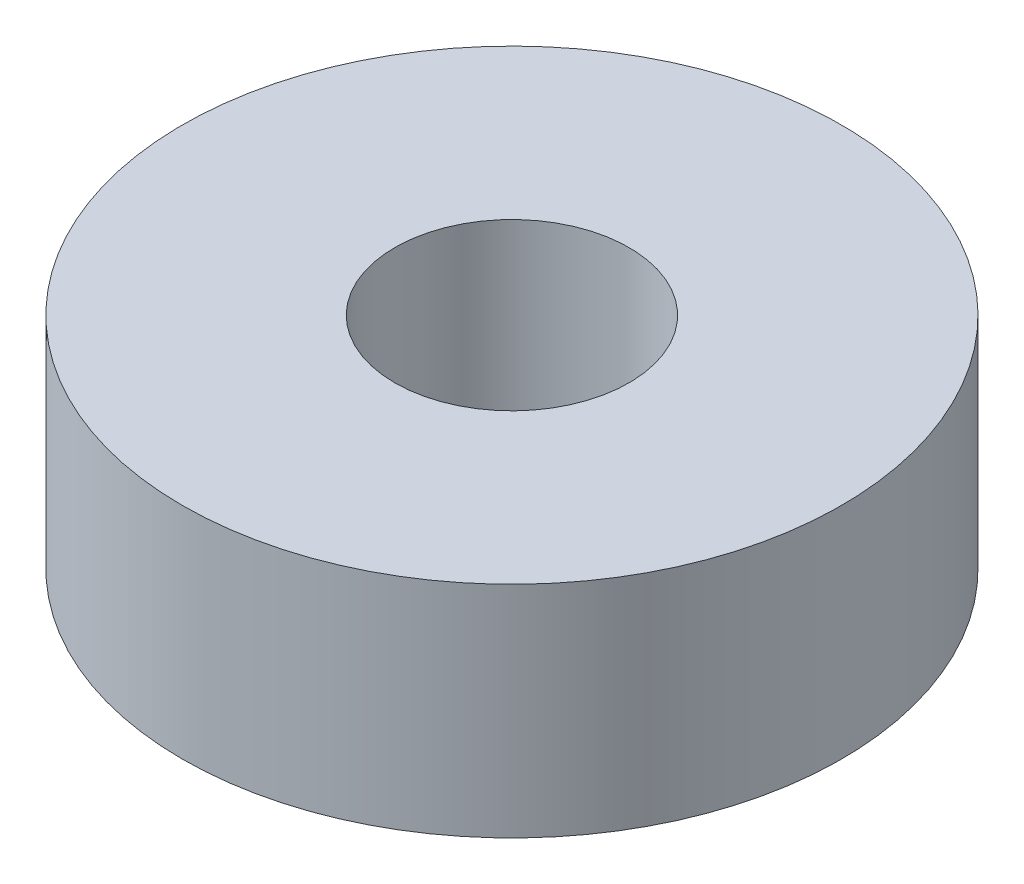
from build123d import *

# Parameters (mm, degrees)
SKETCH_1_R      = 22.5
SKETCH_1_R_2    = 8
EXTRUDE_1_DEPTH = 15


with BuildPart() as part:
    # 草图1 → 凸台-拉伸1 (new body)
    with BuildSketch(Plane(origin=(0, 0, 0), x_dir=(1, 0, 0), z_dir=(0, 1, 0))):
        Circle(SKETCH_1_R)
        Circle(SKETCH_1_R_2, mode=Mode.SUBTRACT)
    extrude(amount=EXTRUDE_1_DEPTH)


solid = part.part
